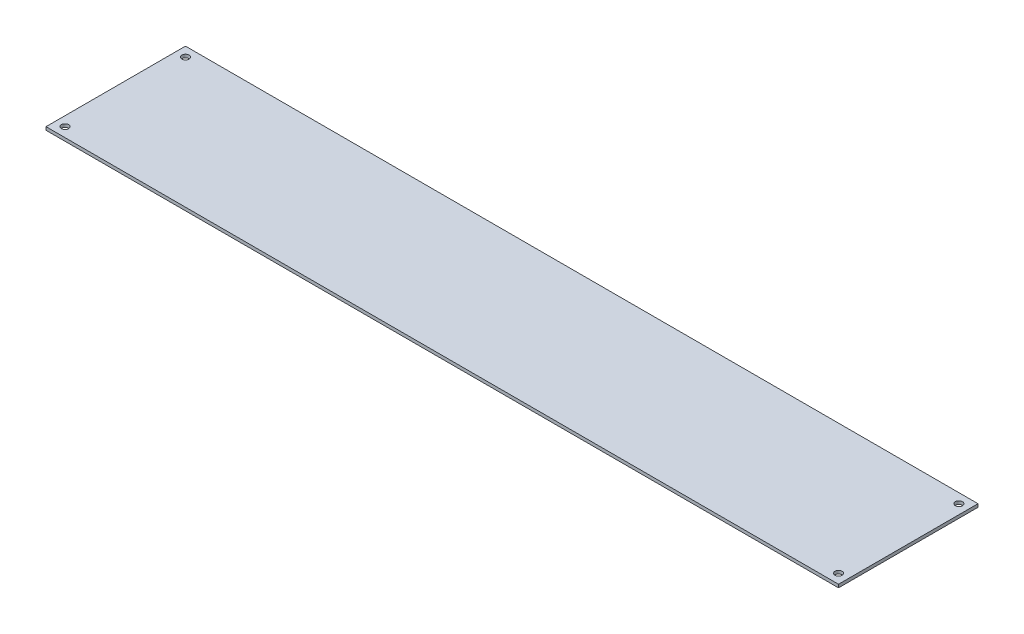
from build123d import *

# Parameters (mm, degrees)
SKETCH1_W                = 500
SKETCH1_H                = 88
BOSS_EXTRUDE1_DEPTH      = 2
M4_CLEARANCE_HOLE1_D     = 4.5
M4_CLEARANCE_HOLE1_DEPTH = 2


with BuildPart() as part:
    # Sketch1 → Boss-Extrude1 (new body)
    with BuildSketch(Plane(origin=(0, 0, 0), x_dir=(1, 0, 0), z_dir=(0, 1, 0))):
        with Locations((250, 44)):
            Rectangle(SKETCH1_W, SKETCH1_H)
    extrude(amount=BOSS_EXTRUDE1_DEPTH)

    # M4 Clearance Hole1
    with Locations(Plane(origin=(0, 2, 0), x_dir=(1, 0, 0), z_dir=(0, 1, 0))):
        with Locations((6, 82), (6, 6), (494, 6), (494, 82)):
            Hole(M4_CLEARANCE_HOLE1_D / 2, depth=M4_CLEARANCE_HOLE1_DEPTH)


solid = part.part
